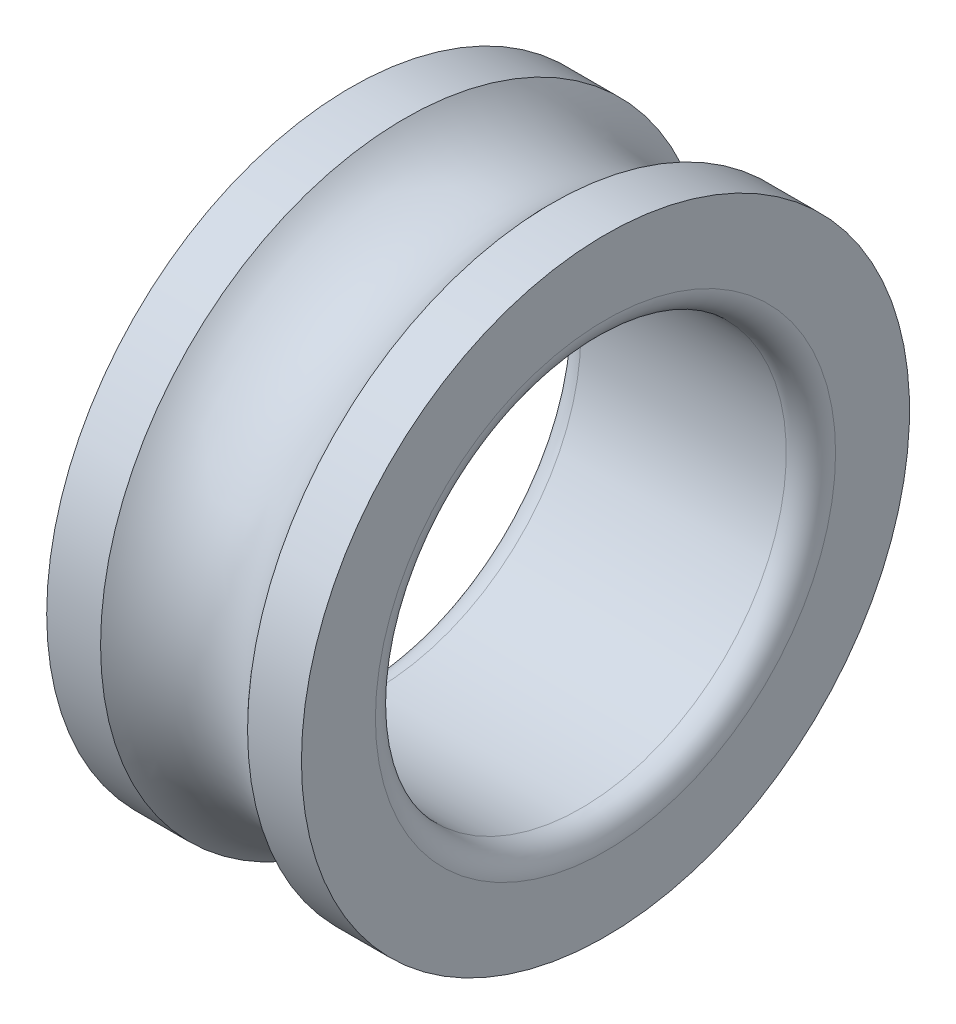
from build123d import *

# Parameters (mm, degrees)
FILLET1_R = 3


with BuildPart() as part:
    # Sketch1 → Revolve1 (revolve)
    with BuildSketch(Plane.XY):
        with BuildLine():
            Line((-15.5, 25), (15.5, 25))
            Line((15.5, 25), (15.5, 37))
            Line((15.5, 37), (8.94427191, 37))
            ThreePointArc((8.94427191, 37), (0, 33), (-8.94427191, 37))
            Line((-8.94427191, 37), (-15.5, 37))
            Line((-15.5, 37), (-15.5, 25))
        make_face()
    revolve(axis=Axis((-22.616352201, 0, 0), (1, 0, 0)))

    # Fillet1
    fillet1_edges = [part.edges().sort_by_distance(p)[0] for p in [
        (15.5, -25, 0),
        (-15.5, -25, 0),
    ]]
    fillet(fillet1_edges, radius=FILLET1_R)


solid = part.part
